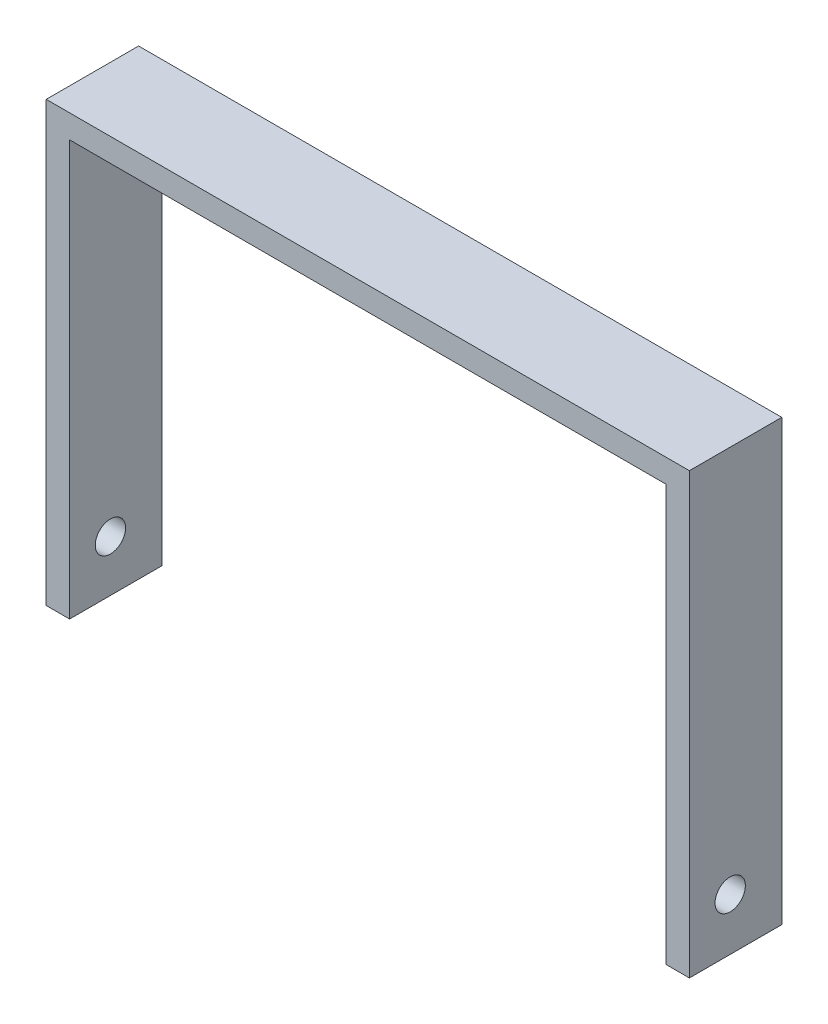
from build123d import *

# Parameters (mm, degrees)
BOSS_EXTRUDE4_DEPTH = 20.066
SKETCH15_R          = 3.293162321
CUT_EXTRUDE4_DEPTH  = 181.61


with BuildPart() as part:
    # Sketch2 → Boss-Extrude4 (new body)
    with BuildSketch(Plane.XY):
        Polygon((-29.763481726, 52.78748547), (-29.763481726, -42.434997301), (-24.683481726, -42.434997301), (-24.683481726, 47.70748547), (104.856518274, 47.70748547), (104.856518274, -42.642464856), (109.936518274, -42.642464856), (109.936518274, 52.78748547), align=None)
    extrude(amount=BOSS_EXTRUDE4_DEPTH)

    # Sketch15 → Cut-Extrude4 (cut)
    with BuildSketch(Plane.ZY.offset(29.763481726)):
        with Locations((11.203431829, -31.335314142)):
            Circle(SKETCH15_R)
    extrude(amount=-CUT_EXTRUDE4_DEPTH, mode=Mode.SUBTRACT)


solid = part.part
